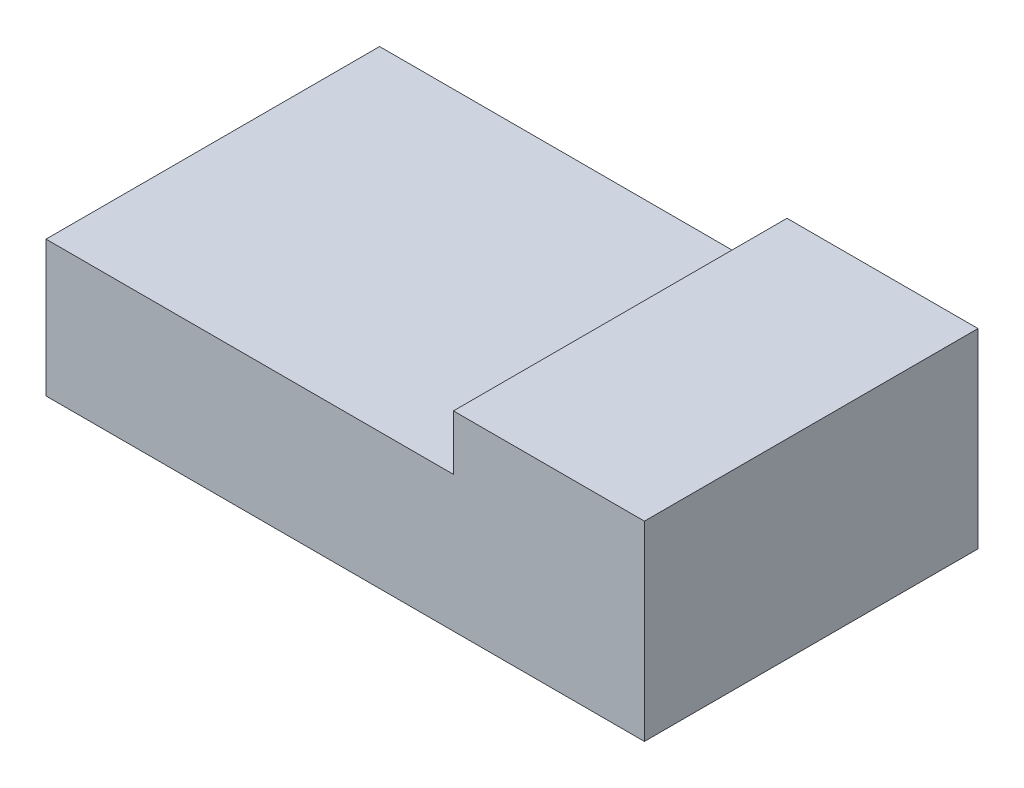
from build123d import *

# Parameters (mm, degrees)
SKETCH1_W           = 47
SKETCH1_H           = 26.2
BOSS_EXTRUDE1_DEPTH = 10.668
SKETCH2_W           = 15
SKETCH2_H           = 26.2
BOSS_EXTRUDE2_DEPTH = 4.318


with BuildPart() as part:
    # Sketch1 → Boss-Extrude1 (new body)
    with BuildSketch(Plane(origin=(0, 0, 0), x_dir=(1, 0, 0), z_dir=(0, 1, 0))):
        with Locations((23.5, -13.1)):
            Rectangle(SKETCH1_W, SKETCH1_H)
    extrude(amount=BOSS_EXTRUDE1_DEPTH)

    # Sketch2 → Boss-Extrude2 (add)
    with BuildSketch(Plane(origin=(0, 10.668, 0), x_dir=(1, 0, 0), z_dir=(0, 1, 0))):
        with Locations((39.5, -13.1)):
            Rectangle(SKETCH2_W, SKETCH2_H)
    extrude(amount=BOSS_EXTRUDE2_DEPTH)


solid = part.part
